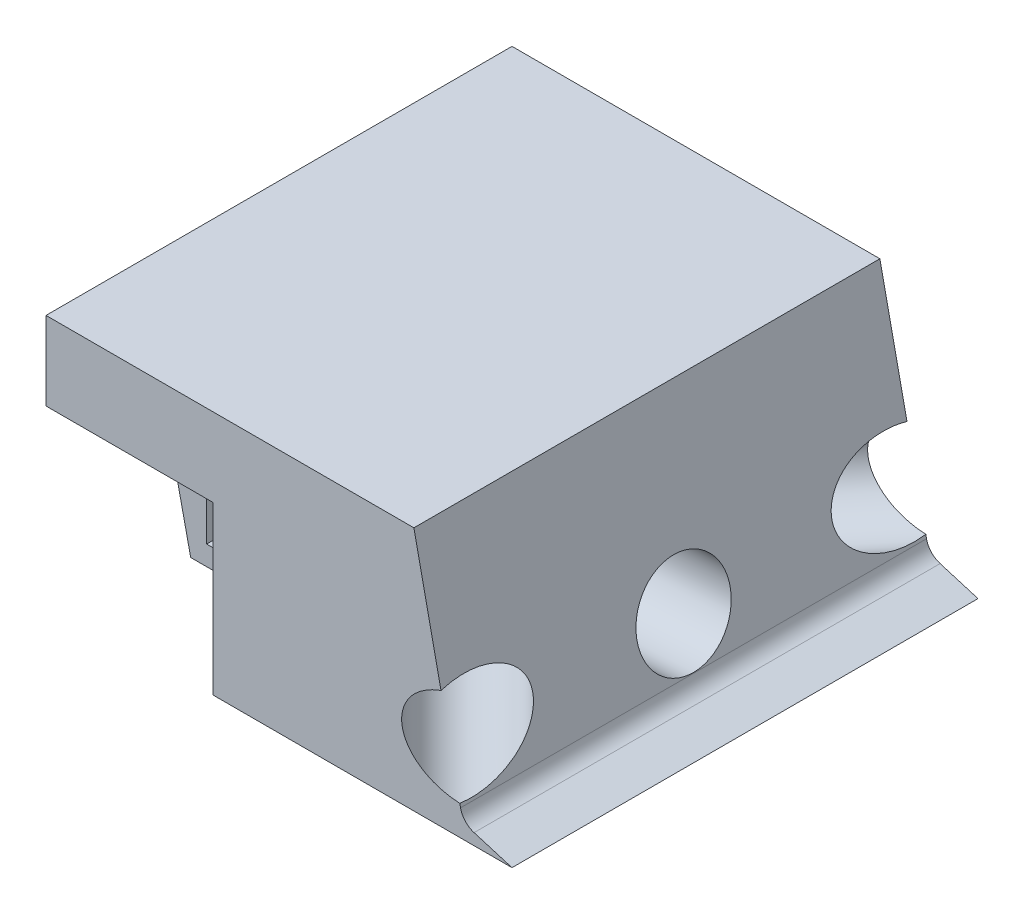
from build123d import *

# Parameters (mm, degrees)
SKETCH1_W           = 95
SKETCH1_H           = 95
BOSS_EXTRUDE1_DEPTH = 50
CUT_EXTRUDE1_DEPTH  = 100
SKETCH3_R           = 9.5
CUT_EXTRUDE2_DEPTH  = 45
CUT_EXTRUDE4_DEPTH  = 45
CUT_EXTRUDE5_DEPTH  = 45
CUT_EXTRUDE6_DEPTH  = 45
CUT_EXTRUDE7_DEPTH  = 45
SKETCH9_R           = 9.5
CUT_EXTRUDE9_DEPTH  = 45
SKETCH11_R          = 9.5
CUT_EXTRUDE10_DEPTH = 45
SKETCH12_W          = 31.985759797
SKETCH12_H          = 95
BOSS_EXTRUDE2_DEPTH = 45
CUT_EXTRUDE11_DEPTH = 100
SKETCH14_R          = 9.5
CUT_EXTRUDE12_DEPTH = 100
SKETCH15_R          = 9.5
CUT_EXTRUDE13_DEPTH = 100
SKETCH16_R          = 9.5
CUT_EXTRUDE14_DEPTH = 100
FILLET2_R           = 4
SKETCH17_W          = 34
SKETCH17_H          = 34
CUT_EXTRUDE16_DEPTH = 22
SKETCH19_W          = 34
SKETCH19_H          = 34
CUT_EXTRUDE17_DEPTH = 22
SKETCH20_W          = 12.5
SKETCH20_H          = 16.5
CUT_EXTRUDE18_DEPTH = 60
CUT_EXTRUDE19_DEPTH = 60


with BuildPart() as part:
    # Sketch1 → Boss-Extrude1 (new body)
    with BuildSketch(Plane(origin=(0, 0, 0), x_dir=(1, 0, 0), z_dir=(0, 1, 0))):
        with Locations((-8.446550514, 2.043801884)):
            Rectangle(SKETCH1_W, SKETCH1_H)
    extrude(amount=BOSS_EXTRUDE1_DEPTH)

    # Sketch2 → Cut-Extrude1 (cut)
    with BuildSketch(Plane.XY.offset(45.456198116)):
        Polygon((39.053449486, 0), (36.353449486, 50), (39.053449486, 50), align=None)
    extrude(amount=-CUT_EXTRUDE1_DEPTH, mode=Mode.SUBTRACT)

    # Sketch3 → Cut-Extrude2 (cut)
    with BuildSketch(Plane(origin=(38.939900735, 2.10275464, 0), x_dir=(0, 0, -1), z_dir=(0.998545181, 0.05392144, 0))):
        with Locations((2.043801884, 13.394181776)):
            Circle(SKETCH3_R)
    extrude(amount=-CUT_EXTRUDE2_DEPTH, mode=Mode.SUBTRACT)

    # Sketch5 → Cut-Extrude4 (cut)
    with BuildSketch(Plane(origin=(0, 50, 0), x_dir=(1, 0, 0), z_dir=(0, 1, 0))):
        Polygon((39.053449486, 49.543801884), (39.053449486, 29.543801884), (19.053449486, 49.543801884), align=None)
        Polygon((39.053449486, -45.456198116), (39.053449486, -25.456198116), (19.053449486, -45.456198116), align=None)
    extrude(amount=-CUT_EXTRUDE4_DEPTH, mode=Mode.SUBTRACT)

    # Sketch6 → Cut-Extrude5 (cut)
    with BuildSketch(Plane(origin=(0, 50, 0), x_dir=(1, 0, 0), z_dir=(0, 1, 0))):
        Polygon((19.053449486, -45.456198116), (12.925569587, -39.328318218), (6.797689689, -45.456198116), align=None)
        Polygon((19.053449486, 49.543801884), (12.925569587, 43.415921985), (6.797689689, 49.543801884), align=None)
    extrude(amount=-CUT_EXTRUDE5_DEPTH, mode=Mode.SUBTRACT)

    # Sketch7 → Cut-Extrude6 (cut)
    with BuildSketch(Plane(origin=(-13.201374315, 0, 13.201374315), x_dir=(0.707106781, 0, 0.707106781), z_dir=(-0.707106781, 0, 0.707106781))):
        Polygon((45.615209271, 5), (42.915209271, 50), (45.615209271, 50), align=None)
    extrude(amount=-CUT_EXTRUDE6_DEPTH, mode=Mode.SUBTRACT)

    # Sketch8 → Cut-Extrude7 (cut)
    with BuildSketch(Plane(origin=(-15.245176199, 0, -15.245176199), x_dir=(-0.707106781, 0, 0.707106781), z_dir=(-0.707106781, 0, -0.707106781))):
        Polygon((-48.505581614, 5), (-45.805581614, 50), (-48.505581614, 50), align=None)
    extrude(amount=-CUT_EXTRUDE7_DEPTH, mode=Mode.SUBTRACT)

    # Sketch9 → Cut-Extrude9 (cut)
    with BuildSketch(Plane(origin=(34.386964646, 2.917830706, -34.386964646), x_dir=(-0.708373873, 0.059677836, -0.70331004), z_dir=(0.705837415, 0.059892291, -0.705837415))):
        with Locations((14.526974541, 11.311121921)):
            Circle(SKETCH9_R)
    extrude(amount=-CUT_EXTRUDE9_DEPTH, mode=Mode.SUBTRACT)

    # Sketch11 → Cut-Extrude10 (cut)
    with BuildSketch(Plane(origin=(32.350494057, 2.745030447, 32.350494057), x_dir=(0.70331004, 0.059677836, -0.708373873), z_dir=(0.705837415, 0.059892291, 0.705837415))):
        with Locations((-10.17752107, 12.964151979)):
            Circle(SKETCH11_R)
    extrude(amount=-CUT_EXTRUDE10_DEPTH, mode=Mode.SUBTRACT)

    # Sketch12 → Boss-Extrude2 (add)
    with BuildSketch(Plane(origin=(0, 5, 0), x_dir=(1, 0, 0), z_dir=(0, 1, 0))):
        with Locations((22.790569588, 2.043801884)):
            Rectangle(SKETCH12_W, SKETCH12_H)
    extrude(amount=BOSS_EXTRUDE2_DEPTH)

    # Sketch13 → Cut-Extrude11 (cut)
    with BuildSketch(Plane.XY.offset(45.456198116)):
        Polygon((39.053449486, 0), (29.053449486, 3), (19.053449486, 50), (49.745275601, 50), align=None)
    extrude(amount=-CUT_EXTRUDE11_DEPTH, mode=Mode.SUBTRACT)

    # Sketch14 → Cut-Extrude12 (cut)
    with BuildSketch(Plane(origin=(-5.994632406, -0.32371015, 0), x_dir=(0, 0, -1), z_dir=(0.998545181, 0.05392144, 0))):
        with Locations((2.043801884, 13.394181776)):
            Circle(SKETCH14_R)
    extrude(amount=CUT_EXTRUDE12_DEPTH, mode=Mode.SUBTRACT)

    # Sketch15 → Cut-Extrude13 (cut)
    with BuildSketch(Plane(origin=(0.587810371, 0.049877364, 0.587810371), x_dir=(0.70331004, 0.059677836, -0.708373873), z_dir=(0.705837415, 0.059892291, 0.705837415))):
        with Locations((-10.17752107, 12.964151979)):
            Circle(SKETCH15_R)
    extrude(amount=CUT_EXTRUDE13_DEPTH, mode=Mode.SUBTRACT)

    # Sketch16 → Cut-Extrude14 (cut)
    with BuildSketch(Plane(origin=(2.62428096, 0.222677624, -2.62428096), x_dir=(-0.708373873, 0.059677836, -0.70331004), z_dir=(0.705837415, 0.059892291, -0.705837415))):
        with Locations((14.526974541, 11.311121921)):
            Circle(SKETCH16_R)
    extrude(amount=CUT_EXTRUDE14_DEPTH, mode=Mode.SUBTRACT)

    # Fillet2
    fillet2_edges = [part.edges().sort_by_distance(p)[0] for p in [
        (29.053449486, 3, -2.043801884),
    ]]
    fillet(fillet2_edges, radius=FILLET2_R)

    # Sketch17 → Cut-Extrude16 (cut)
    with BuildSketch(Plane.XY.offset(45.456198116)):
        with Locations((-38.946550514, 17)):
            Rectangle(SKETCH17_W, SKETCH17_H)
    extrude(amount=-CUT_EXTRUDE16_DEPTH, mode=Mode.SUBTRACT)

    # Sketch19 → Cut-Extrude17 (cut)
    with BuildSketch(Plane(origin=(0, 0, -49.543801884), x_dir=(-1, 0, 0), z_dir=(0, 0, -1))):
        with Locations((38.946550514, 17)):
            Rectangle(SKETCH19_W, SKETCH19_H)
    extrude(amount=-CUT_EXTRUDE17_DEPTH, mode=Mode.SUBTRACT)

    # Sketch20 → Cut-Extrude18 (cut)
    with BuildSketch(Plane.XY.offset(23.456198116)):
        with Locations((-38.946550514, 12.25)):
            Rectangle(SKETCH20_W, SKETCH20_H)
    extrude(amount=-CUT_EXTRUDE18_DEPTH, mode=Mode.SUBTRACT)

    # Sketch21 → Cut-Extrude19 (cut)
    with BuildSketch(Plane.XY.offset(23.456198116)):
        Polygon((-55.946550514, 34), (-48.446550514, 0), (-55.946550514, 0), align=None)
    extrude(amount=-CUT_EXTRUDE19_DEPTH, mode=Mode.SUBTRACT)


solid = part.part
